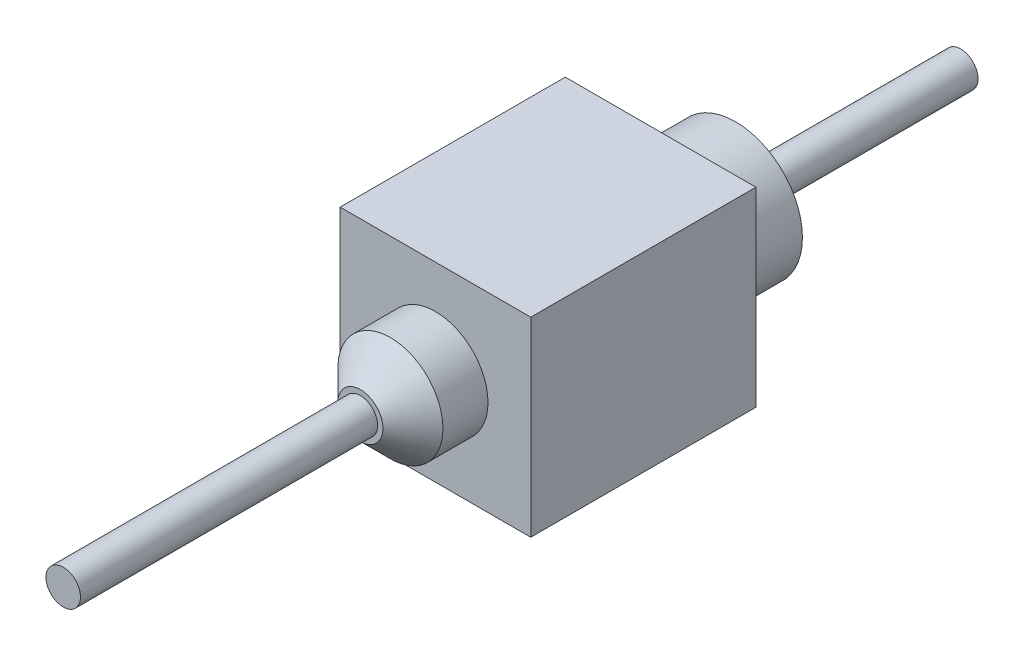
from build123d import *

# Parameters (mm, degrees)
SKETCH1_W           = 2.54
SKETCH1_H           = 2.54
BOSS_EXTRUDE1_DEPTH = 3
SKETCH2_R           = 0.23
BOSS_EXTRUDE2_DEPTH = 4
SKETCH3_R           = 0.89
BOSS_EXTRUDE3_DEPTH = 1
SKETCH4_R           = 0.23
BOSS_EXTRUDE4_DEPTH = 4.96
SKETCH5_R           = 0.7
BOSS_EXTRUDE5_DEPTH = 1
CHAMFER1_SIZE       = 0.4


with BuildPart() as part:
    # Sketch1 → Boss-Extrude1 (new body)
    with BuildSketch(Plane.XY):
        Rectangle(SKETCH1_W, SKETCH1_H)
    extrude(amount=BOSS_EXTRUDE1_DEPTH)

    # Sketch2 → Boss-Extrude2 (add)
    with BuildSketch(Plane(origin=(0, 0, 0), x_dir=(-1, 0, 0), z_dir=(0, 0, -1))):
        Circle(SKETCH2_R)
    extrude(amount=BOSS_EXTRUDE2_DEPTH)

    # Sketch3 → Boss-Extrude3 (add)
    with BuildSketch(Plane(origin=(0, 0, 0), x_dir=(-1, 0, 0), z_dir=(0, 0, -1))):
        Circle(SKETCH3_R)
    extrude(amount=BOSS_EXTRUDE3_DEPTH)

    # Sketch4 → Boss-Extrude4 (add)
    with BuildSketch(Plane.XY.offset(3)):
        Circle(SKETCH4_R)
    extrude(amount=BOSS_EXTRUDE4_DEPTH)

    # Sketch5 → Boss-Extrude5 (add)
    with BuildSketch(Plane.XY.offset(3)):
        Circle(SKETCH5_R)
    extrude(amount=BOSS_EXTRUDE5_DEPTH)

    # Chamfer1
    chamfer1_edges = [part.edges().sort_by_distance(p)[0] for p in [
        (-0.7, 0, 4),
    ]]
    chamfer(chamfer1_edges, length=CHAMFER1_SIZE)


solid = part.part
